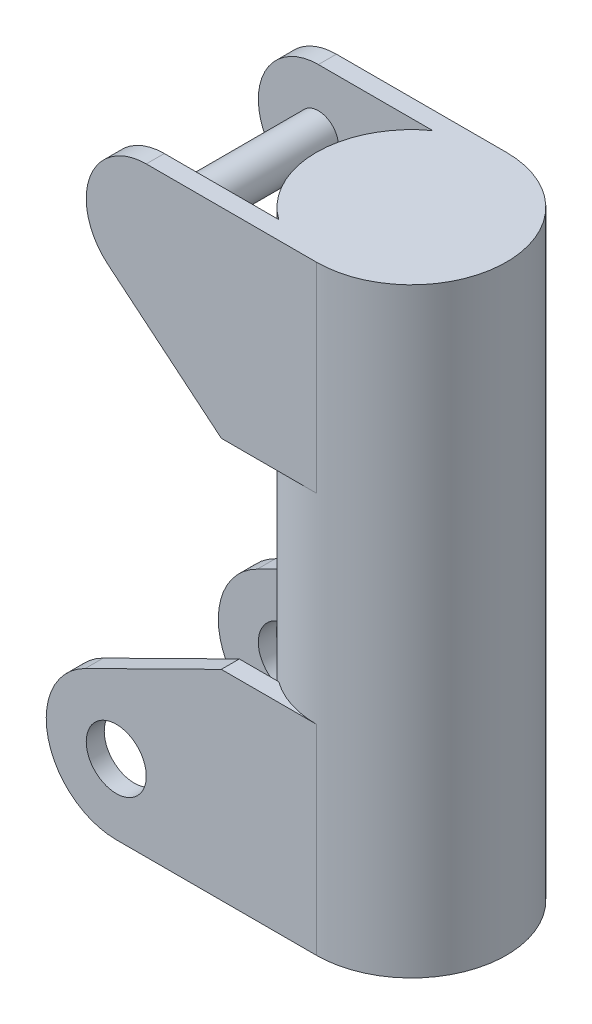
from build123d import *

# Parameters (mm, degrees)
SKETCH1_R           = 95
BOSS_EXTRUDE1_DEPTH = 600
SHELL1_T            = 10
SKETCH2_R           = 30
BOSS_EXTRUDE2_DEPTH = 18
SKETCH4_R           = 20
BOSS_EXTRUDE3_DEPTH = 95


with BuildPart() as part:
    # Sketch1 → Boss-Extrude1 (new body)
    with BuildSketch(Plane(origin=(0, 0, 0), x_dir=(1, 0, 0), z_dir=(0, 1, 0))):
        Circle(SKETCH1_R)
    extrude(amount=BOSS_EXTRUDE1_DEPTH)

    # Shell1 (no face opened: a closed hollow body)
    add(offset(amount=-SHELL1_T, mode=Mode.PRIVATE), mode=Mode.SUBTRACT)

    # Sketch2 → Boss-Extrude2 (add)
    with BuildSketch(Plane(origin=(0, 0, -95), x_dir=(-1, 0, 0), z_dir=(0, 0, -1))):
        with BuildLine():
            Line((0, 0), (95, 0))
            Line((95, 0), (200, 0))
            ThreePointArc((200, 0), (268.163356789, 54.070254514), (231.023569289, 132.749805964))
            Line((231.023569289, 132.749805964), (95, 200))
            Line((95, 200), (0, 200))
            Line((0, 200), (0, 0))
        make_face()
        with Locations((200, 70)):
            Circle(SKETCH2_R, mode=Mode.SUBTRACT)
        with BuildLine():
            Line((0, 600), (95, 600))
            Line((95, 600), (170, 600))
            ThreePointArc((170, 600), (226.448348767, 560.336762809), (208.265889327, 493.786130718))
            Line((208.265889327, 493.786130718), (95, 400))
            Line((95, 400), (0, 400))
            Line((0, 400), (0, 600))
        make_face()
    boss_extrude2 = extrude(amount=-BOSS_EXTRUDE2_DEPTH)

    # Mirror1: Boss-Extrude2 across plane
    add(boss_extrude2.mirror(Plane(origin=(0, 0, 0), x_dir=(1, 0, 0), z_dir=(0, 0, -1))))

    # Sketch4 → Boss-Extrude3 (add, symmetric)
    with BuildSketch(Plane.XY):
        with Locations((-170, 540)):
            Circle(SKETCH4_R)
    extrude(amount=BOSS_EXTRUDE3_DEPTH, both=True)


solid = part.part
